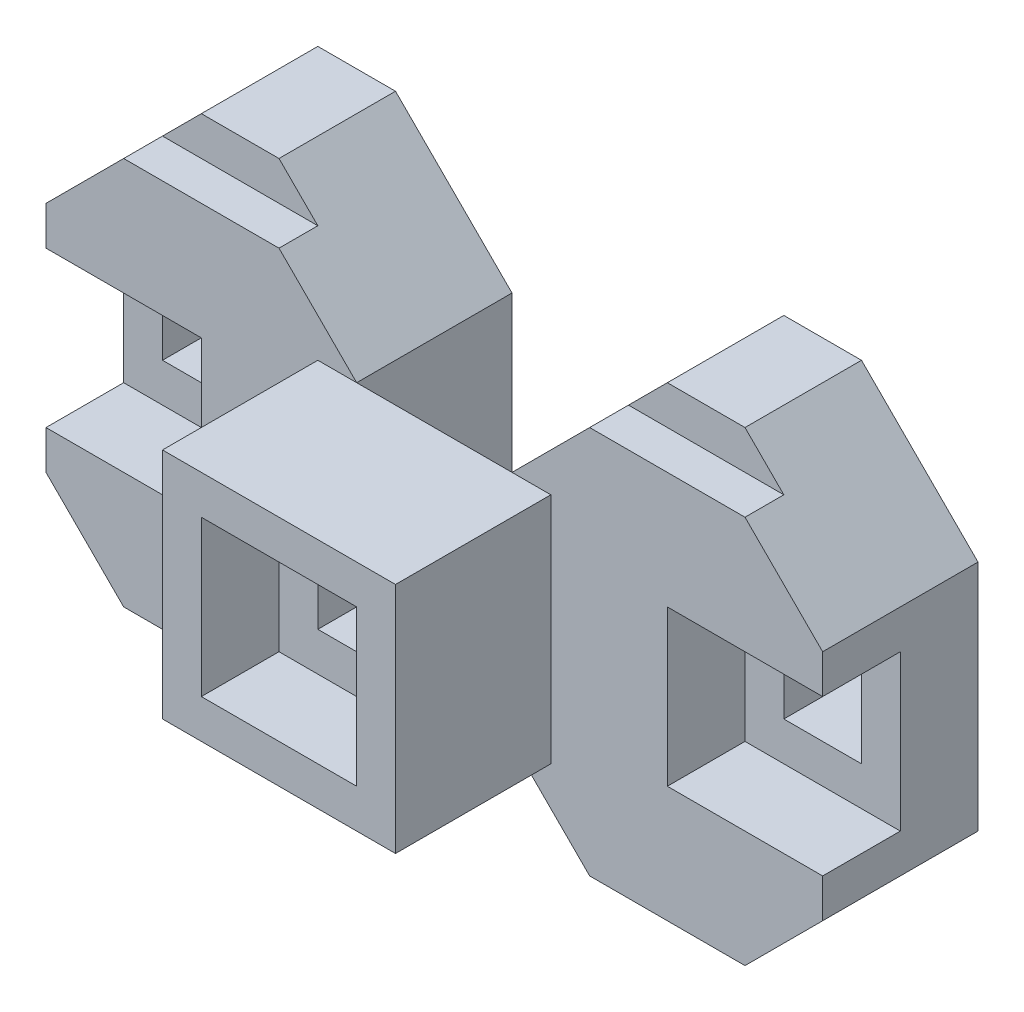
from build123d import *

# Parameters (mm, degrees)
BOSS_EXTRUDE1_DEPTH = 20
SKETCH2_W           = 20
SKETCH2_H           = 20
CUT_EXTRUDE1_DEPTH  = 10
SKETCH3_W           = 10
SKETCH3_H           = 10
CUT_EXTRUDE2_DEPTH  = 194
BOSS_EXTRUDE3_DEPTH = 15
SKETCH6_W           = 30
SKETCH6_H           = 30
BOSS_EXTRUDE4_DEPTH = 20
SKETCH7_W           = 20
SKETCH7_H           = 20
CUT_EXTRUDE3_DEPTH  = 10
SKETCH8_W           = 10
SKETCH8_H           = 10
CUT_EXTRUDE4_DEPTH  = 41
BOSS_EXTRUDE7_DEPTH = 20
BOSS_EXTRUDE8_DEPTH = 15
SKETCH12_W          = 20
SKETCH12_H          = 20
CUT_EXTRUDE5_DEPTH  = 10
SKETCH13_W          = 10
SKETCH13_H          = 10
CUT_EXTRUDE6_DEPTH  = 31


with BuildPart() as part:
    # Sketch1 → Boss-Extrude1 (new body)
    with BuildSketch(Plane.XY):
        Polygon((-40, 0), (-40, 30), (-30, 40), (-10, 40), (0, 30), (0, 0), (-10, -10), (-30, -10), align=None)
    extrude(amount=BOSS_EXTRUDE1_DEPTH)

    # Sketch2 → Cut-Extrude1 (cut)
    with BuildSketch(Plane.XY.offset(20)):
        with Locations((-30, 15)):
            Rectangle(SKETCH2_W, SKETCH2_H)
    extrude(amount=-CUT_EXTRUDE1_DEPTH, mode=Mode.SUBTRACT)

    # Sketch3 → Cut-Extrude2 (cut)
    with BuildSketch(Plane.XY.offset(10)):
        with Locations((-30, 15)):
            Rectangle(SKETCH3_W, SKETCH3_H)
    extrude(amount=-CUT_EXTRUDE2_DEPTH, mode=Mode.SUBTRACT)

    # Sketch5 → Boss-Extrude3 (add)
    with BuildSketch(Plane(origin=(0, 0, 0), x_dir=(-1, 0, 0), z_dir=(0, 0, -1))):
        Polygon((30, -10), (25, -15), (15, -15), (10, -10), align=None)
        Polygon((30, 40), (25, 45), (15, 45), (10, 40), align=None)
    extrude(amount=-BOSS_EXTRUDE3_DEPTH)

    # Sketch6 → Boss-Extrude4 (add)
    with BuildSketch(Plane.XY.offset(20)):
        with Locations((10, 15)):
            Rectangle(SKETCH6_W, SKETCH6_H)
    extrude(amount=BOSS_EXTRUDE4_DEPTH)

    # Sketch7 → Cut-Extrude3 (cut)
    with BuildSketch(Plane.XY.offset(40)):
        with Locations((10, 15)):
            Rectangle(SKETCH7_W, SKETCH7_H)
    extrude(amount=-CUT_EXTRUDE3_DEPTH, mode=Mode.SUBTRACT)

    # Sketch8 → Cut-Extrude4 (cut)
    with BuildSketch(Plane.XY.offset(30)):
        with Locations((10, 15)):
            Rectangle(SKETCH8_W, SKETCH8_H)
    extrude(amount=-CUT_EXTRUDE4_DEPTH, mode=Mode.SUBTRACT)

    # Sketch10 → Boss-Extrude7 (add)
    with BuildSketch(Plane(origin=(0, 0, 20), x_dir=(-1, 0, 0), z_dir=(0, 0, -1))):
        Polygon((-20, 30), (-30, 40), (-50, 40), (-60, 30), (-60, 0), (-50, -10), (-30, -10), (-20, 0), align=None)
    extrude(amount=BOSS_EXTRUDE7_DEPTH)

    # Sketch11 → Boss-Extrude8 (add)
    with BuildSketch(Plane(origin=(0, 0, 0), x_dir=(-1, 0, 0), z_dir=(0, 0, -1))):
        Polygon((-35, 45), (-45, 45), (-50, 40), (-30, 40), align=None)
        Polygon((-50, -10), (-30, -10), (-35, -15), (-45, -15), align=None)
    extrude(amount=-BOSS_EXTRUDE8_DEPTH)

    # Sketch12 → Cut-Extrude5 (cut)
    with BuildSketch(Plane.XY.offset(20)):
        with Locations((50, 15)):
            Rectangle(SKETCH12_W, SKETCH12_H)
    extrude(amount=-CUT_EXTRUDE5_DEPTH, mode=Mode.SUBTRACT)

    # Sketch13 → Cut-Extrude6 (cut)
    with BuildSketch(Plane.XY.offset(10)):
        with Locations((50, 15)):
            Rectangle(SKETCH13_W, SKETCH13_H)
    extrude(amount=-CUT_EXTRUDE6_DEPTH, mode=Mode.SUBTRACT)


solid = part.part
